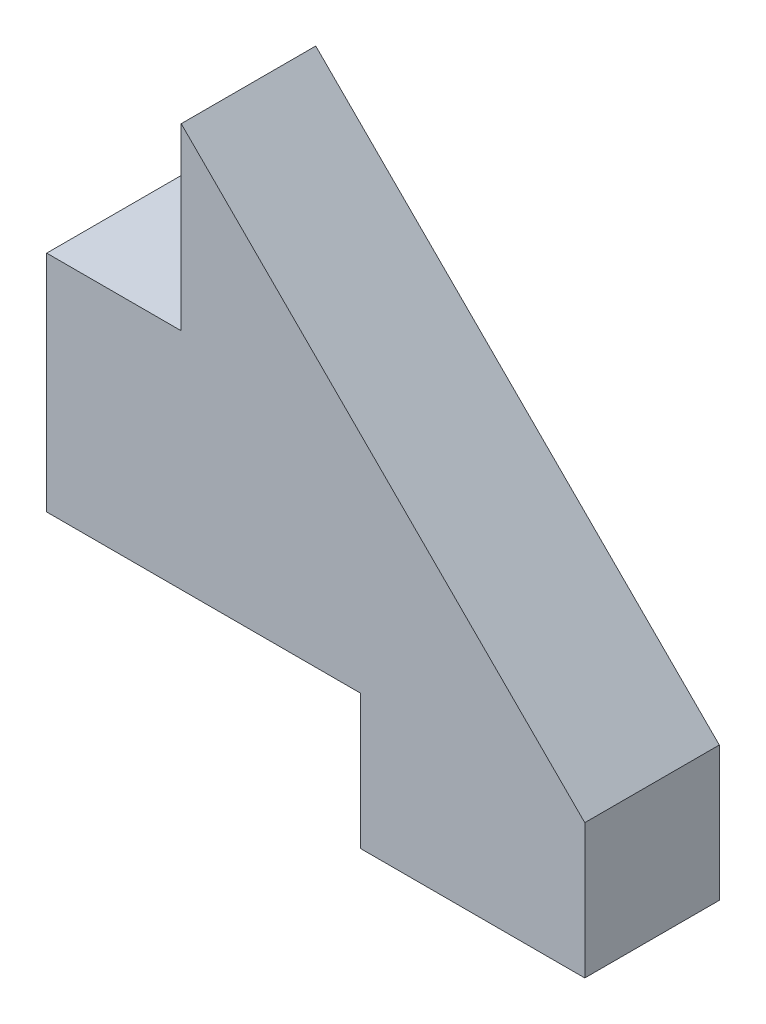
from build123d import *

# Parameters (mm, degrees)
BOSS_EXTRUDE1_DEPTH = 6


with BuildPart() as part:
    # Sketch1 → Boss-Extrude1 (new body)
    with BuildSketch(Plane.XY):
        Polygon((0, 0), (0, 10), (6, 10), (6, 18), (24, 0), (24, -6), (14, -6), (14, 0), align=None)
    extrude(amount=BOSS_EXTRUDE1_DEPTH)


solid = part.part
